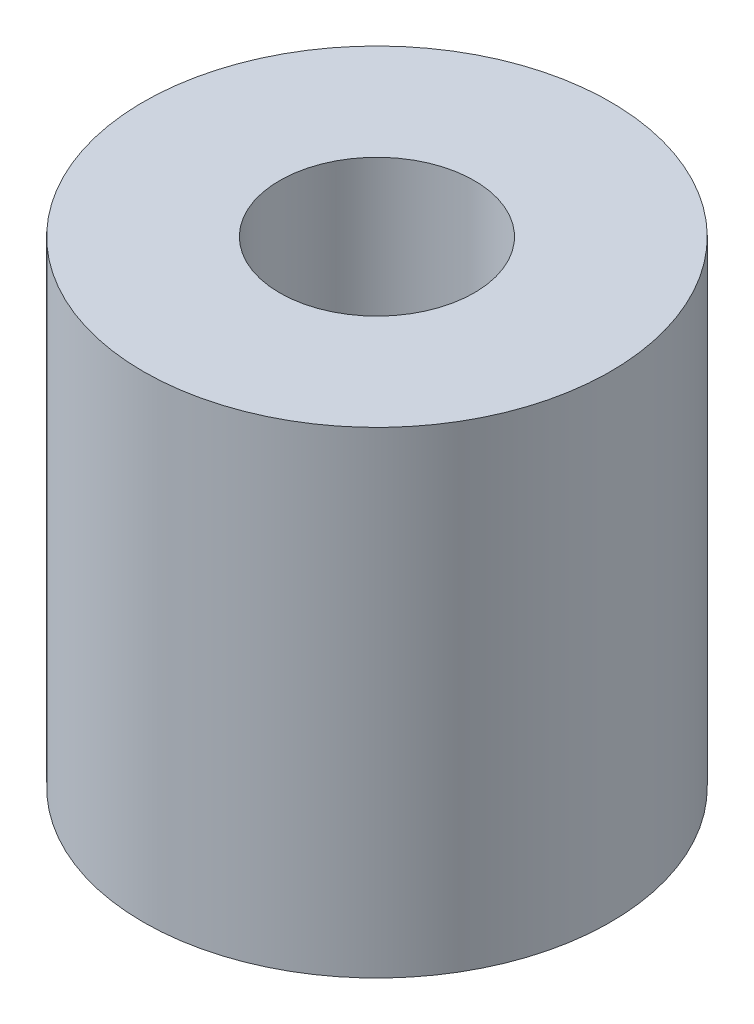
from build123d import *

# Parameters (mm, degrees)
SKETCH1_R           = 48
SKETCH1_R_2         = 20
BOSS_EXTRUDE1_DEPTH = 98


with BuildPart() as part:
    # Sketch1 → Boss-Extrude1 (new body)
    with BuildSketch(Plane(origin=(0, 0, 0), x_dir=(1, 0, 0), z_dir=(0, 1, 0))):
        Circle(SKETCH1_R)
        Circle(SKETCH1_R_2, mode=Mode.SUBTRACT)
    extrude(amount=BOSS_EXTRUDE1_DEPTH)


solid = part.part
